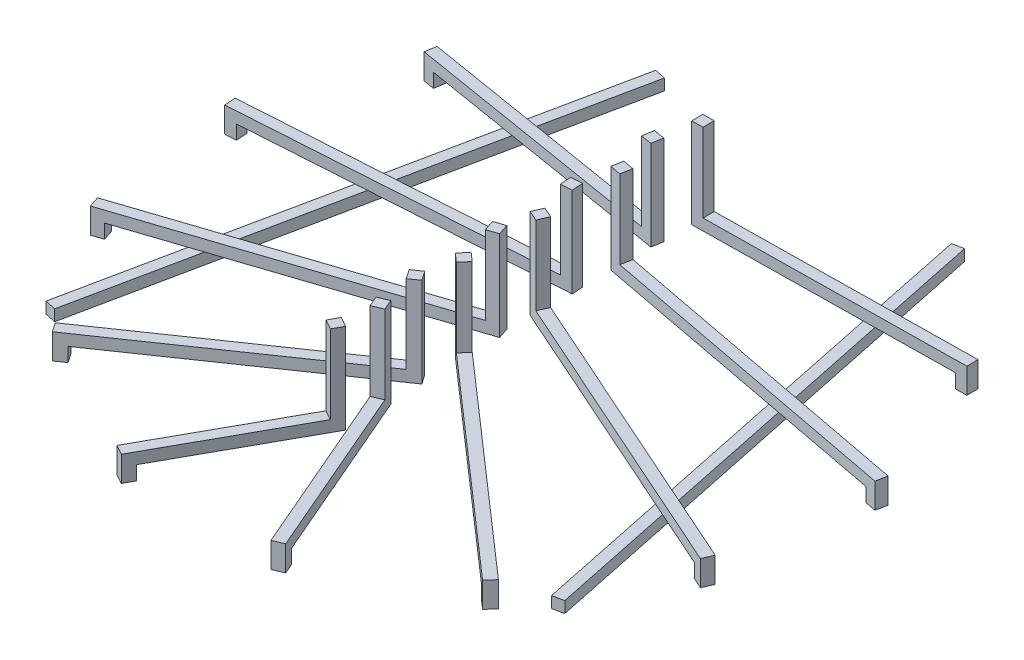
from build123d import *

# Parameters (mm, degrees)
EXTRUDE_THIN1_DEPTH    = 0.2
EXTRUDE_THIN1_2_DEPTH  = 0.2
EXTRUDE_THIN1_3_DEPTH  = 0.2
EXTRUDE_THIN1_4_DEPTH  = 0.2
EXTRUDE_THIN1_5_DEPTH  = 0.2
EXTRUDE_THIN1_6_DEPTH  = 0.2
EXTRUDE_THIN1_7_DEPTH  = 0.2
EXTRUDE_THIN1_8_DEPTH  = 0.2
EXTRUDE_THIN1_9_DEPTH  = 0.2
EXTRUDE_THIN1_10_DEPTH = 0.2
BOSS_EXTRUDE1_DEPTH    = 1.4
BOSS_EXTRUDE3_START    = -0.2
BOSS_EXTRUDE3_DEPTH    = 0.45
BOSS_EXTRUDE4_DEPTH    = 0.2
BOSS_EXTRUDE4_2_DEPTH  = 0.2


with BuildPart() as part:
    # Sketch2 → Extrude-Thin1 (new body)
    with BuildSketch(Plane(origin=(0, 0, 0), x_dir=(1, 0, 0), z_dir=(0, 1, 0))):
        Polygon((-0.03148464, -0.160641292), (-5.407828036, -1.944063837), (-5.344858755, -2.133892364), (0.03148464, -0.350469819), align=None)
    extrude(amount=EXTRUDE_THIN1_DEPTH)



with BuildPart() as body_2:
    # Sketch2 → Extrude-Thin1 2 (new body)
    with BuildSketch(Plane(origin=(0, 0, 0), x_dir=(1, 0, 0), z_dir=(0, 1, 0))):
        Polygon((0.001402442, 3.100009835), (4.733559671, 3.166382128), (4.730754787, 3.366362459), (-0.001402442, 3.299990165), align=None)
    extrude(amount=EXTRUDE_THIN1_2_DEPTH)


with BuildPart() as body_3:
    # Sketch2 → Extrude-Thin1 3 (new body)
    with BuildSketch(Plane(origin=(0, 0, 0), x_dir=(1, 0, 0), z_dir=(0, 1, 0))):
        Polygon((-0.056722562, -1.595421534), (-3.869677847, -4.221580558), (-3.756232723, -4.386293046), (0.056722562, -1.760134022), align=None)
    extrude(amount=EXTRUDE_THIN1_3_DEPTH)


with BuildPart() as body_4:
    # Sketch2 → Extrude-Thin1 4 (new body)
    with BuildSketch(Plane(origin=(0, 0, 0), x_dir=(1, 0, 0), z_dir=(0, 1, 0))):
        Polygon((-0.091839415, -2.428455564), (1.284225654, -5.622482125), (1.467904485, -5.543348775), (0.091839415, -2.349322214), align=None)
    extrude(amount=EXTRUDE_THIN1_4_DEPTH)


with BuildPart() as body_5:
    # Sketch2 → Extrude-Thin1 5 (new body)
    with BuildSketch(Plane(origin=(0, 0, 0), x_dir=(1, 0, 0), z_dir=(0, 1, 0))):
        Polygon((-0.01866868, 1.679535829), (5.689407347, 0.594843963), (5.726744706, 0.79132786), (0.01866868, 1.876019726), align=None)
    extrude(amount=EXTRUDE_THIN1_5_DEPTH)


with BuildPart() as body_6:
    # Sketch2 → Extrude-Thin1 6 (new body)
    with BuildSketch(Plane(origin=(0, 0, 0), x_dir=(1, 0, 0), z_dir=(0, 1, 0))):
        Polygon((-0.040685453, 0.264206259), (5.335657943, -2.130327397), (5.417028848, -1.947628804), (0.040685453, 0.446904852), align=None)
    extrude(amount=EXTRUDE_THIN1_6_DEPTH)


with BuildPart() as body_7:
    # Sketch2 → Extrude-Thin1 7 (new body)
    with BuildSketch(Plane(origin=(0, 0, 0), x_dir=(1, 0, 0), z_dir=(0, 1, 0))):
        Polygon((-0.065860903, -1.041915198), (3.747094382, -4.379185334), (3.878816188, -4.22868827), (0.065860903, -0.891418135), align=None)
    extrude(amount=EXTRUDE_THIN1_7_DEPTH)


with BuildPart() as body_8:
    # Sketch2 → Extrude-Thin1 8 (new body)
    with BuildSketch(Plane(origin=(0, 0, 0), x_dir=(1, 0, 0), z_dir=(0, 1, 0))):
        Polygon((-0.087465517, -3.051525436), (-1.463530587, -5.534440887), (-1.288599553, -5.631390014), (0.087465517, -3.148474564), align=None)
    extrude(amount=EXTRUDE_THIN1_8_DEPTH)


with BuildPart() as body_9:
    # Sketch2 → Extrude-Thin1 9 (new body)
    with BuildSketch(Plane(origin=(0, 0, 0), x_dir=(1, 0, 0), z_dir=(0, 1, 0))):
        Polygon((0.016212428, 2.587565924), (-4.715944801, 3.365049328), (-4.748369657, 3.167695259), (-0.016212428, 2.390211854), align=None)
    extrude(amount=EXTRUDE_THIN1_9_DEPTH)


with BuildPart() as body_10:
    # Sketch2 → Extrude-Thin1 10 (new body)
    with BuildSketch(Plane(origin=(0, 0, 0), x_dir=(1, 0, 0), z_dir=(0, 1, 0))):
        Polygon((-0.006530803, 1.166453182), (-5.714606829, 0.792872427), (-5.701545223, 0.593299396), (0.006530803, 0.966880152), align=None)
    extrude(amount=EXTRUDE_THIN1_10_DEPTH)


with BuildPart() as part_1:
    add(part.part)

    add(body_2.part)  # Boss-Extrude1 merges body 2

    add(body_3.part)  # Boss-Extrude1 merges body 3

    add(body_4.part)  # Boss-Extrude1 merges body 4

    add(body_5.part)  # Boss-Extrude1 merges body 5

    add(body_6.part)  # Boss-Extrude1 merges body 6

    add(body_7.part)  # Boss-Extrude1 merges body 7

    add(body_8.part)  # Boss-Extrude1 merges body 8

    add(body_9.part)  # Boss-Extrude1 merges body 9

    add(body_10.part)  # Boss-Extrude1 merges body 10
    # Sketch3 → Boss-Extrude1 (add)
    with BuildSketch(Plane(origin=(0, 0.2, 0), x_dir=(1, 0, 0), z_dir=(0, 1, 0))):
        Polygon((-0.001402442, 3.299990165), (0.001402442, 3.100009835), (0.201382773, 3.102814719), (0.198577888, 3.30279505), align=None)
        Polygon((0.016212428, 2.587565924), (-0.181141642, 2.619990779), (-0.213566497, 2.42263671), (-0.016212428, 2.390211854), align=None)
        Polygon((0.01866868, 1.876019726), (-0.01866868, 1.679535829), (0.177815217, 1.64219847), (0.215152576, 1.838682367), align=None)
        Polygon((-0.006530803, 1.166453182), (0.006530803, 0.966880152), (-0.193042227, 0.953818545), (-0.206103834, 1.153391575), align=None)
        Polygon((0.040685453, 0.446904852), (-0.040685453, 0.264206259), (0.14201314, 0.182835354), (0.223384045, 0.365533947), align=None)
        Polygon((-0.03148464, -0.160641292), (0.03148464, -0.350469819), (-0.158343887, -0.4134391), (-0.221313167, -0.223610572), align=None)
        Polygon((0.065860903, -0.891418135), (-0.065860903, -1.041915198), (0.08463616, -1.173637004), (0.216357966, -1.023139941), align=None)
        Polygon((-0.056722562, -1.595421534), (0.056722562, -1.760134022), (-0.107989926, -1.873579146), (-0.22143505, -1.708866658), align=None)
        Polygon((0.091839415, -2.349322214), (-0.091839415, -2.428455564), (-0.012706065, -2.612134395), (0.170972766, -2.533001044), align=None)
        Polygon((-0.087465517, -3.051525436), (0.087465517, -3.148474564), (-0.00948361, -3.323405598), (-0.184414644, -3.226456471), align=None)
    extrude(amount=BOSS_EXTRUDE1_DEPTH)

    # Sketch4 → Boss-Extrude3 (add)
    with BuildSketch(Plane.XZ.offset(BOSS_EXTRUDE3_START)):
        Polygon((4.633569506, -3.164979686), (4.630764621, -3.364960017), (4.830744952, -3.367764901), (4.833549836, -3.167784571), align=None)
        Polygon((5.787649295, -0.576175284), (5.824986654, -0.77265918), (5.628502757, -0.809996539), (5.591165398, -0.613512643), align=None)
        Polygon((5.427007239, 2.171012849), (5.508378144, 1.988314257), (5.325679552, 1.906943352), (5.244308646, 2.089641944), align=None)
        Polygon((3.822342914, 4.445046236), (3.954064719, 4.294549173), (3.803567656, 4.162827368), (3.671845851, 4.313324431), align=None)
        Polygon((1.323792329, 5.714321541), (1.50747116, 5.63518819), (1.42833781, 5.45150936), (1.244658979, 5.53064271), align=None)
        Polygon((-1.51200515, 5.621906404), (-1.337074116, 5.718855531), (-1.240124989, 5.543924497), (-1.415056023, 5.446975369), align=None)
        Polygon((-3.952034091, 4.27830312), (-3.838588967, 4.443015608), (-3.673876479, 4.329570484), (-3.787321603, 4.164857996), align=None)
        Polygon((-5.439773019, 2.165377004), (-5.502742299, 1.975548477), (-5.312913772, 1.912579197), (-5.249944492, 2.102407724), align=None)
        Polygon((-5.814393345, -0.786341623), (-5.801331738, -0.586768593), (-5.601758708, -0.5998302), (-5.614820314, -0.79940323), align=None)
        Polygon((-4.847046691, -3.183907687), (-4.814621836, -3.381261756), (-4.617267766, -3.348836901), (-4.649692622, -3.151482831), align=None)
    extrude(amount=BOSS_EXTRUDE3_DEPTH)


with BuildPart() as body_2_2:
    # Sketch5 → Boss-Extrude4 (new body)
    with BuildSketch(Plane(origin=(0, -0.25, 0), x_dir=(1, 0, 0), z_dir=(0, 1, 0))):
        Polygon((4.422449747, -3.818262244), (2.553895996, 5.168922401), (2.749708492, 5.209634391), (4.618262244, -3.777550253), align=None)
    extrude(amount=BOSS_EXTRUDE4_DEPTH)


with BuildPart() as body_3_2:
    # Sketch5 → Boss-Extrude4 2 (new body)
    with BuildSketch(Plane(origin=(0, -0.25, 0), x_dir=(1, 0, 0), z_dir=(0, 1, 0))):
        Polygon((-4.618262244, -3.777550253), (-2.749708492, 5.209634391), (-2.553895996, 5.168922401), (-4.422449747, -3.818262244), align=None)
    extrude(amount=BOSS_EXTRUDE4_2_DEPTH)


solid = Compound([part_1.part, body_2_2.part, body_3_2.part])
